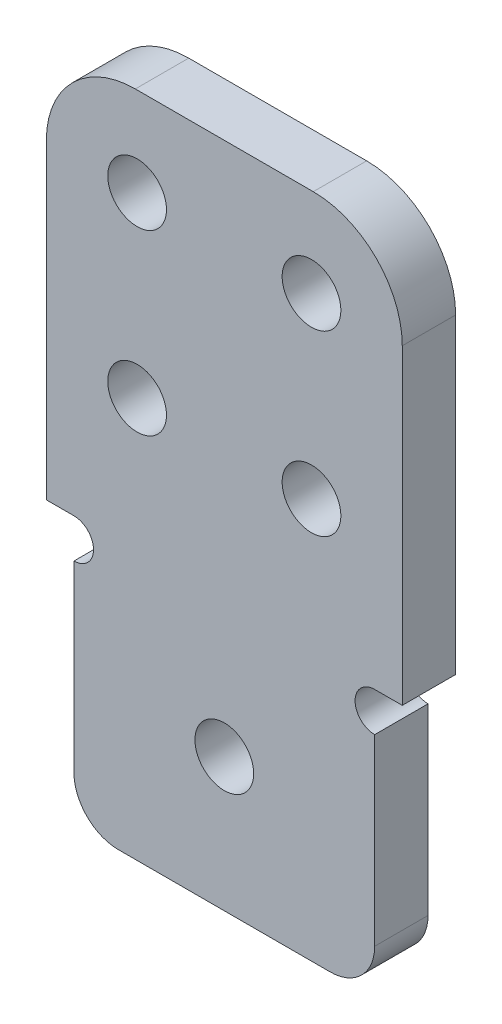
from build123d import *
from OCP.BRepFilletAPI import BRepFilletAPI_MakeFillet

# Parameters (mm, degrees)
SKETCH_2_R      = 1.65
EXTRUDE_1_DEPTH = 3
FILLET_3_R1     = 2.5
FILLET_3_R2     = 5


with BuildPart() as part:
    # ｽｹｯﾁ2 → ﾎﾞｽ - 押し出し1 (new body)
    with BuildSketch(Plane.XY):
        with BuildLine():
            Line((-8.45, -27.5), (8.45, -27.5))
            Line((8.45, -27.5), (8.45, -14.7))
            ThreePointArc((8.45, -14.7), (7.35, -13.6), (8.45, -12.5))
            Line((8.45, -12.5), (10, -12.5))
            Line((10, -12.5), (10, 10))
            Line((10, 10), (-10, 10))
            Line((-10, 10), (-10, -12.5))
            Line((-10, -12.5), (-8.45, -12.5))
            ThreePointArc((-8.45, -12.5), (-7.35, -13.6), (-8.45, -14.7))
            Line((-8.45, -14.7), (-8.45, -27.5))
        make_face()
        with Locations((-4.9, 5)):
            Circle(SKETCH_2_R, mode=Mode.SUBTRACT)
        with Locations((-4.9, -5)):
            Circle(SKETCH_2_R, mode=Mode.SUBTRACT)
        with Locations((4.9, -5)):
            Circle(SKETCH_2_R, mode=Mode.SUBTRACT)
        with Locations((4.9, 5)):
            Circle(SKETCH_2_R, mode=Mode.SUBTRACT)
        with Locations((0, -20)):
            Circle(SKETCH_2_R, mode=Mode.SUBTRACT)
    extrude(amount=EXTRUDE_1_DEPTH)

    # ﾌｨﾚｯﾄ3: one fillet with a radius per group of edges: ONE call of the kernel's fillet builder (fillet() takes one radius for all edges)
    fillet_3_edges_1 = [part.edges().sort_by_distance(p)[0] for p in [
        (-8.45, -27.5, 1.5),
        (8.45, -27.5, 1.5),
    ]]
    fillet_3_edges_2 = [part.edges().sort_by_distance(p)[0] for p in [
        (10, 10, 1.5),
        (-10, 10, 1.5),
    ]]
    fillet_3 = BRepFilletAPI_MakeFillet(part.part.solid().wrapped)
    for e in fillet_3_edges_1:
        fillet_3.Add(FILLET_3_R1, e.wrapped)
    for e in fillet_3_edges_2:
        fillet_3.Add(FILLET_3_R2, e.wrapped)
    add(Compound.cast(fillet_3.Shape()), mode=Mode.REPLACE)


solid = part.part
